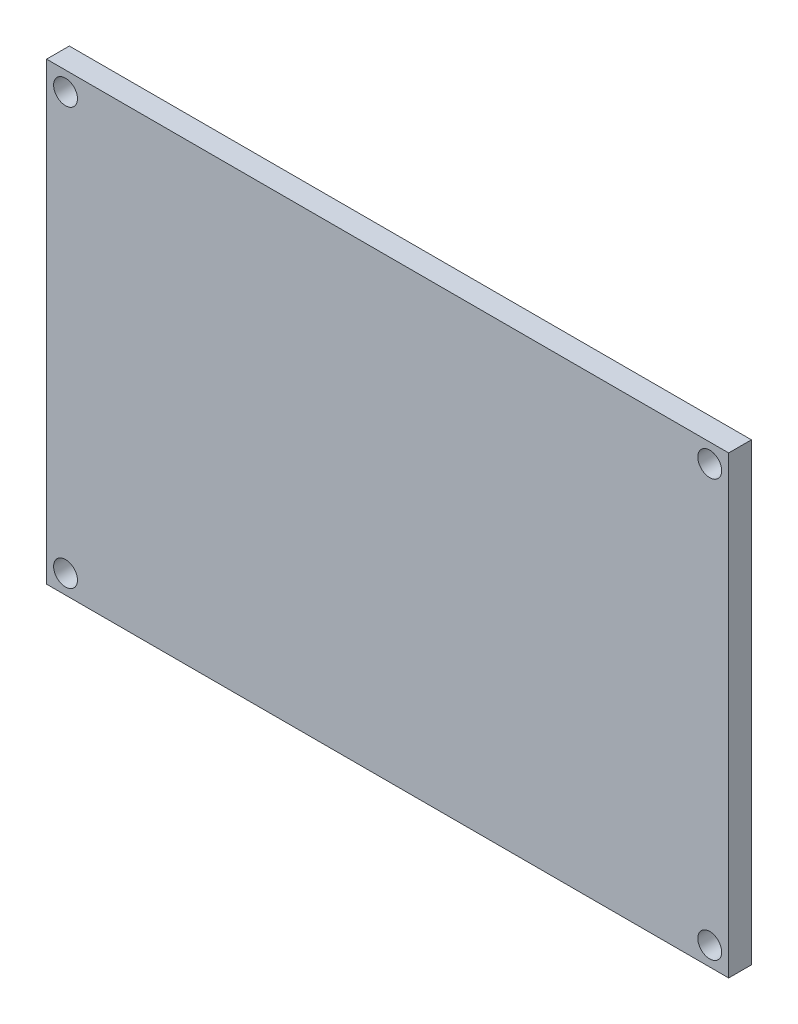
from build123d import *

# Parameters (mm, degrees)
SKETCH1_W           = 90
SKETCH1_H           = 60
SKETCH1_R           = 1.575
BOSS_EXTRUDE1_DEPTH = 3


with BuildPart() as part:
    # Sketch1 → Boss-Extrude1 (new body)
    with BuildSketch(Plane.XY):
        Rectangle(SKETCH1_W, SKETCH1_H)
        with Locations((-42.5, 27.5)):
            Circle(SKETCH1_R, mode=Mode.SUBTRACT)
        with Locations((42.5, 27.5)):
            Circle(SKETCH1_R, mode=Mode.SUBTRACT)
        with Locations((-42.5, -27.5)):
            Circle(SKETCH1_R, mode=Mode.SUBTRACT)
        with Locations((42.5, -27.5)):
            Circle(SKETCH1_R, mode=Mode.SUBTRACT)
    extrude(amount=BOSS_EXTRUDE1_DEPTH)


solid = part.part
